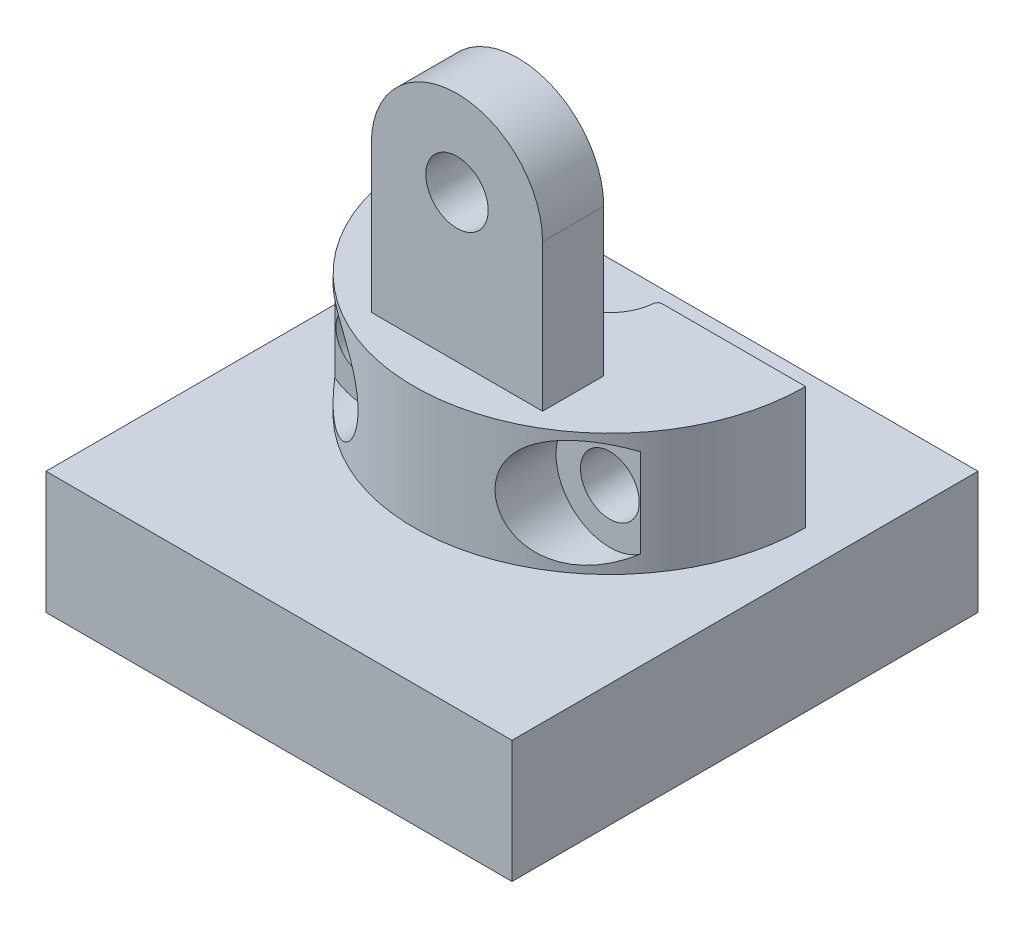
from build123d import *

# Parameters (mm, degrees)
BOSS_EXTRUDE1_DEPTH           = 2.5
SKETCH2_W                     = 7
SKETCH2_H                     = 2.5
BOSS_EXTRUDE2_DEPTH           = 9.5
CUT_EXTRUDE1_DEPTH            = 9.5
SKETCH4_R                     = 1.275
CUT_EXTRUDE2_DEPTH            = 9.5
CBORE_FOR_M2_SHCS1_AT_2_COUNT = 2
CBORE_FOR_M2_SHCS1_AT_2_PITCH = 10
SKETCH8_R                     = 2.2
CUT_EXTRUDE3_DEPTH            = 9.5
SKETCH11_W                    = 19.05
SKETCH11_H                    = 19.05
BOSS_EXTRUDE3_DEPTH           = 5
FILLET1_R                     = 0.2


with BuildPart() as part:
    # Sketch1 → Boss-Extrude1 (new body, symmetric)
    with BuildSketch(Plane(origin=(0, 0, 0), x_dir=(1, 0, 0), z_dir=(0, 1, 0))):
        with BuildLine():
            Line((1.96, 0), (8, 0))
            ThreePointArc((8, 0), (0, -8), (-8, 0))
            Line((-8, 0), (-1.96, 0))
            ThreePointArc((-1.96, 0), (0, -1.96), (1.96, 0))
        make_face()
    extrude(amount=BOSS_EXTRUDE1_DEPTH, both=True)

    # Sketch2 → Boss-Extrude2 (add)
    with BuildSketch(Plane(origin=(0, 2.5, 0), x_dir=(1, 0, 0), z_dir=(0, 1, 0))):
        with Locations((0, -5)):
            Rectangle(SKETCH2_W, SKETCH2_H)
    extrude(amount=BOSS_EXTRUDE2_DEPTH)

    # Sketch3 → Cut-Extrude1 (cut)
    with BuildSketch(Plane(origin=(0, 0, 3.75), x_dir=(-1, 0, 0), z_dir=(0, 0, -1))):
        with BuildLine():
            Line((-3.5, 8.5), (-3.5, 14.886359519))
            Line((-3.5, 14.886359519), (0, 16.809201746))
            Line((0, 16.809201746), (3.5, 14.5))
            Line((3.5, 14.5), (3.5, 8.5))
            ThreePointArc((3.5, 8.5), (0, 12), (-3.5, 8.5))
        make_face()
    extrude(amount=-CUT_EXTRUDE1_DEPTH, mode=Mode.SUBTRACT)

    # Sketch4 → Cut-Extrude2 (cut)
    with BuildSketch(Plane(origin=(0, 0, 3.75), x_dir=(-1, 0, 0), z_dir=(0, 0, -1))):
        with Locations((0, 8.5)):
            Circle(SKETCH4_R)
    extrude(amount=-CUT_EXTRUDE2_DEPTH, mode=Mode.SUBTRACT)

    # Sketch7 → CBORE for M2 SHCS1 (revolve, cut)
    with BuildSketch(Plane(origin=(5, 0, 7), x_dir=(0, -1, 0), z_dir=(1, 0, 0))):
        Polygon((0, 0), (0, 7), (1.2, 7), (1.2, 2), (2.2, 2), (2.2, 0), align=None)
    cbore_for_m2_shcs1 = revolve(axis=Axis((5, 0, 13.35), (0, 0, -1)), mode=Mode.SUBTRACT)

    # CBORE for M2 SHCS1 at 2: CBORE for M2 SHCS1 ×2
    with Locations(*[(-i * CBORE_FOR_M2_SHCS1_AT_2_PITCH, 0, 0) for i in range(1, CBORE_FOR_M2_SHCS1_AT_2_COUNT)]):
        add(cbore_for_m2_shcs1, mode=Mode.SUBTRACT)

    # Sketch8 → Cut-Extrude3 (cut)
    with BuildSketch(Plane(origin=(0, 0, 7), x_dir=(-1, 0, 0), z_dir=(0, 0, -1))):
        with Locations((-5, 0)):
            Circle(SKETCH8_R)
        with Locations((5, 0)):
            Circle(SKETCH8_R)
    extrude(amount=-CUT_EXTRUDE3_DEPTH, mode=Mode.SUBTRACT)

    # Sketch11 → Boss-Extrude3 (add)
    with BuildSketch(Plane.XZ.offset(2.5)):
        with Locations((0, 4)):
            Rectangle(SKETCH11_W, SKETCH11_H)
    extrude(amount=BOSS_EXTRUDE3_DEPTH)

    # Fillet1
    fillet1_edges = [part.edges().sort_by_distance(p)[0] for p in [
        (1.96, 0, 0),
        (-1.96, 0, 0),
    ]]
    fillet(fillet1_edges, radius=FILLET1_R)


solid = part.part
